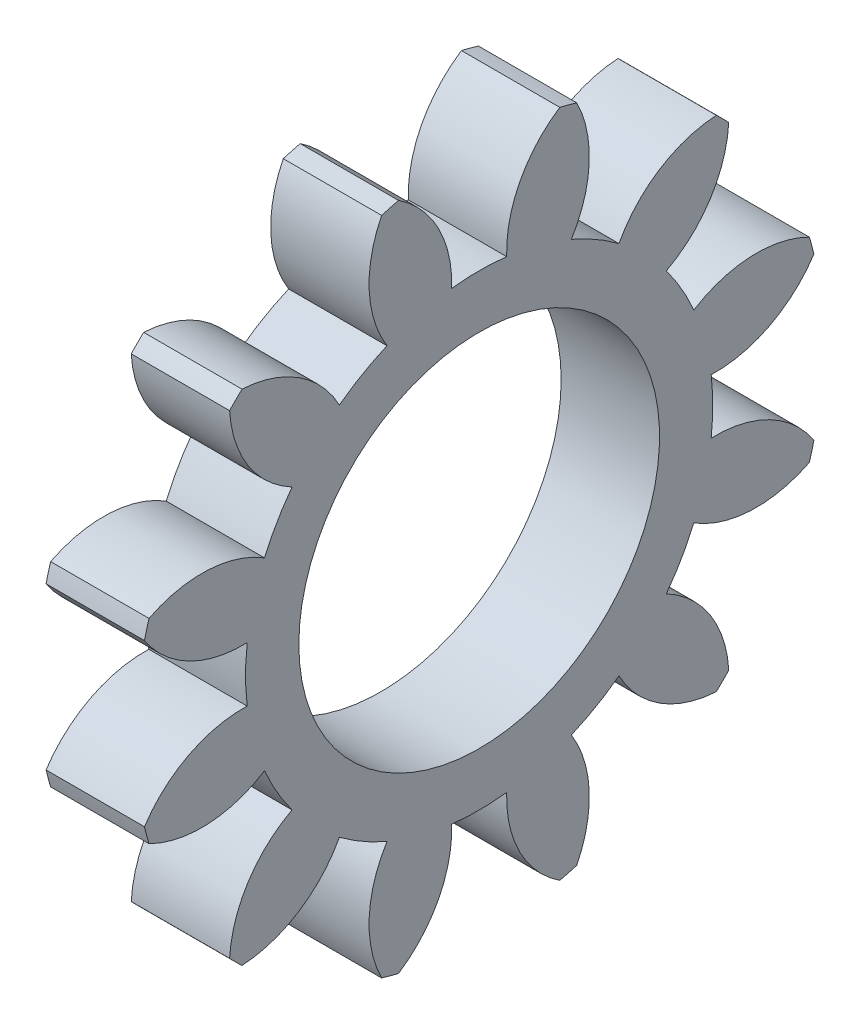
from build123d import *

# Parameters (mm, degrees)
BASPROSKE_W     = 6
BASPROSKE_H     = 21
TOOTHCUT_DEPTH  = 31.298514815
TEETHCUTS_COUNT = 12
TEETHCUTS_ANGLE = 330
BORSKE_R        = 11
BORE_DEPTH      = 50.0000508


with BuildPart() as part:
    # BasProSke → Base-Revolve (revolve)
    with BuildSketch(Plane(origin=(0, 0, 0), x_dir=(1, 0, 0), z_dir=(0, 1, 0)), mode=Mode.PRIVATE) as base_revolve_sk:
        with Locations((3, 10.5)):
            Rectangle(BASPROSKE_W, BASPROSKE_H)
    revolve(base_revolve_sk.sketch.rotate(Axis((-10, 0, 0), (1, 0, 0)), 180), axis=Axis((-10, 0, 0), (1, 0, 0)))

    # TooCutSke → ToothCut (cut, through all)
    with BuildSketch(Plane(origin=(0, 0, 0), x_dir=(0, 0, -1), z_dir=(1, 0, 0))):
        with BuildLine():
            ThreePointArc((1.676853263, 14.149988132), (0, 14.249), (-1.676853263, 14.149988132))
            ThreePointArc((-1.676853263, 14.149988132), (-2.484641508, 17.722586807), (-4.945579042, 20.435476337))
            ThreePointArc((-4.945579042, 20.435476337), (0, 21.0254), (4.945579042, 20.435476337))
            ThreePointArc((4.945579042, 20.435476337), (2.484641508, 17.722586807), (1.676853263, 14.149988132))
        make_face()
    toothcut = extrude(amount=TOOTHCUT_DEPTH, mode=Mode.SUBTRACT)

    # TeethCuts: ToothCut ×12 about axis
    teethcuts_axis = Axis((-10, 0, 0), (1, 0, 0))
    for i in range(1, TEETHCUTS_COUNT):
        add(toothcut.rotate(teethcuts_axis, i * TEETHCUTS_ANGLE / (TEETHCUTS_COUNT - 1)), mode=Mode.SUBTRACT)

    # BorSke → Bore (cut, symmetric)
    with BuildSketch(Plane(origin=(0, 0, 0), x_dir=(0, 0, -1), z_dir=(1, 0, 0))):
        with Locations(Location((0, 0, 0), (0, 0, 180))):
            Circle(BORSKE_R)
    extrude(amount=BORE_DEPTH, both=True, mode=Mode.SUBTRACT)


solid = part.part
